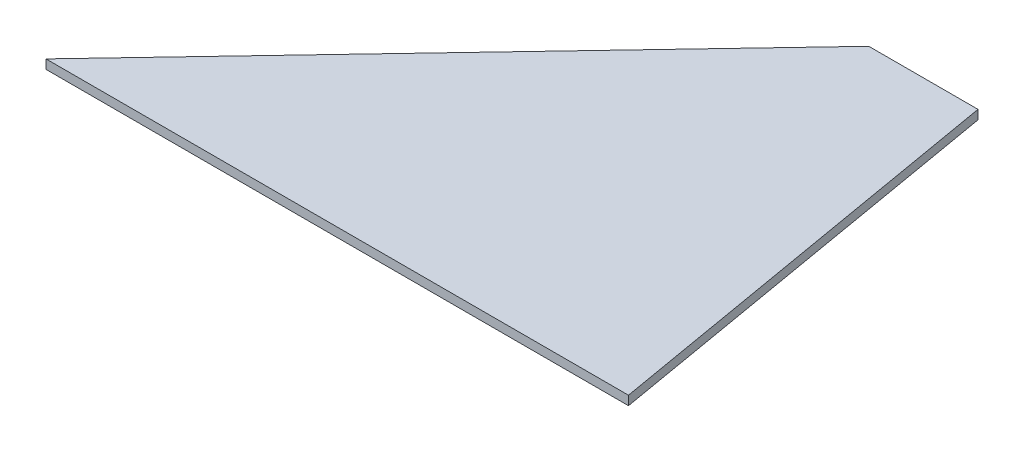
from build123d import *

# Parameters (mm, degrees)
BOSS_EXTRUDE1_DEPTH = 3.175


with BuildPart() as part:
    # Sketch1 → Boss-Extrude1 (new body)
    with BuildSketch(Plane(origin=(0, 0, 0), x_dir=(1, 0, 0), z_dir=(0, 1, 0))):
        Polygon((-203.2, 0), (0, 0), (-25.4, 147.32), (-63.5, 147.32), align=None)
    extrude(amount=BOSS_EXTRUDE1_DEPTH)


solid = part.part
